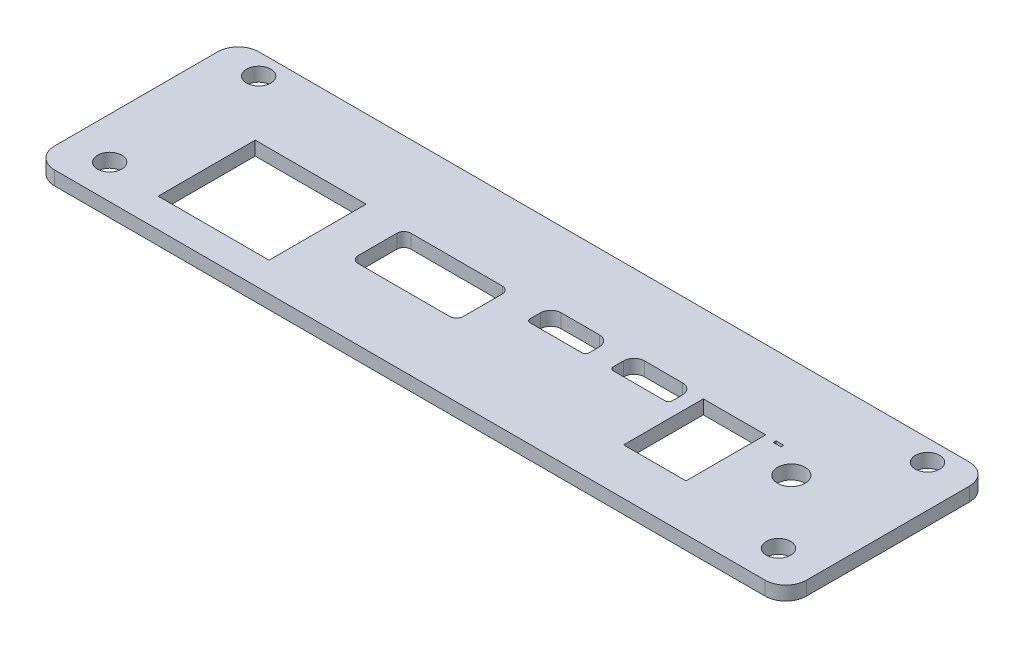
from build123d import *

# Parameters (mm, degrees)
SKETCH1_W           = 108.5
SKETCH1_H           = 29.5
BOSS_EXTRUDE1_DEPTH = 2
SKETCH2_R           = 1.75
CUT_EXTRUDE1_DEPTH  = 3
FILLET1_R           = 3
SKETCH5_R           = 2
SKETCH5_W           = 16
SKETCH5_H           = 14
SKETCH5_W_2         = 15.2
SKETCH5_H_2         = 7.6
SKETCH5_W_3         = 1.1
SKETCH5_H_3         = 0.4
SKETCH5_W_4         = 9
SKETCH5_H_4         = 11.5
CUT_EXTRUDE2_DEPTH  = 3
FILLET2_R           = 1
FILLET3_R           = 1.5
FILLET4_R           = 0.5


with BuildPart() as part:
    # Sketch1 → Boss-Extrude1 (new body)
    with BuildSketch(Plane(origin=(0, 0, 0), x_dir=(1, 0, 0), z_dir=(0, 1, 0))):
        with Locations((54.25, 14.75)):
            Rectangle(SKETCH1_W, SKETCH1_H)
    extrude(amount=BOSS_EXTRUDE1_DEPTH)

    # Sketch2 → Cut-Extrude1 (cut, through all)
    with BuildSketch(Plane(origin=(0, 2, 0), x_dir=(1, 0, 0), z_dir=(0, 1, 0))):
        with Locations((6, 26.45)):
            Circle(SKETCH2_R)
        with Locations((6, 4.95)):
            Circle(SKETCH2_R)
        with Locations((102.5, 4.95)):
            Circle(SKETCH2_R)
        with Locations((102.5, 26.45)):
            Circle(SKETCH2_R)
    extrude(amount=-CUT_EXTRUDE1_DEPTH, mode=Mode.SUBTRACT)

    # Fillet1
    fillet1_edges = [part.edges().sort_by_distance(p)[0] for p in [
        (0, 1, -29.5),
        (108.5, 1, -29.5),
        (108.5, 1, 0),
        (0, 1, 0),
    ]]
    fillet(fillet1_edges, radius=FILLET1_R)

    # Sketch5 → Cut-Extrude2 (cut, through all)
    with BuildSketch(Plane(origin=(0, 2, 0), x_dir=(1, 0, 0), z_dir=(0, 1, 0))):
        with Locations((94.303253972, 15)):
            Circle(SKETCH5_R)
        with Locations((21.75, 11.2)):
            Rectangle(SKETCH5_W, SKETCH5_H)
        with Locations((43.2, 14)):
            Rectangle(SKETCH5_W_2, SKETCH5_H_2)
        Polygon((55.903253972, 18.2), (55.903253972, 15.2), (64.403253972, 15.2), (64.403253972, 18.2), (64.403253972, 18.7), (55.903253972, 18.7), align=None)
        with Locations((89.453253972, 18)):
            Rectangle(SKETCH5_W_3, SKETCH5_H_3)
        Polygon((67.903253972, 18.2), (67.903253972, 15.2), (76.403253972, 15.2), (76.403253972, 18.2), (76.403253972, 18.7), (67.903253972, 18.7), align=None)
        with Locations((82.903253972, 12.45)):
            Rectangle(SKETCH5_W_4, SKETCH5_H_4)
    extrude(amount=-CUT_EXTRUDE2_DEPTH, mode=Mode.SUBTRACT)

    # Fillet2
    fillet2_edges = [part.edges().sort_by_distance(p)[0] for p in [
        (50.8, 1, -10.2),
        (35.6, 1, -10.2),
        (35.6, 1, -17.8),
        (50.8, 1, -17.8),
    ]]
    fillet(fillet2_edges, radius=FILLET2_R)

    # Fillet3
    fillet3_edges = [part.edges().sort_by_distance(p)[0] for p in [
        (67.903253972, 1, -18.7),
        (76.403253972, 1, -18.7),
        (55.903253972, 1, -18.7),
        (64.403253972, 1, -18.7),
    ]]
    fillet(fillet3_edges, radius=FILLET3_R)

    # Fillet4
    fillet4_edges = [part.edges().sort_by_distance(p)[0] for p in [
        (76.403253972, 1, -15.2),
        (67.903253972, 1, -15.2),
        (64.403253972, 1, -15.2),
        (55.903253972, 1, -15.2),
    ]]
    fillet(fillet4_edges, radius=FILLET4_R)


solid = part.part
